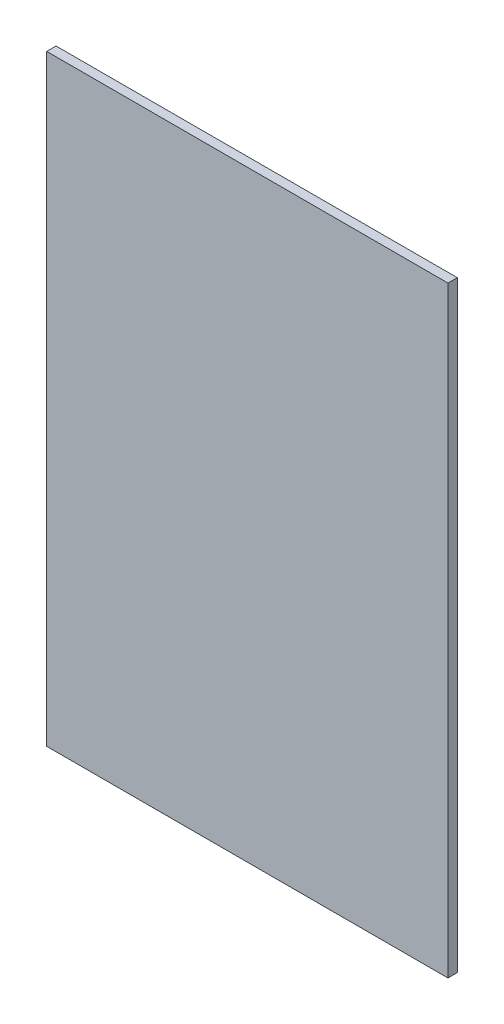
from build123d import *

# Parameters (mm, degrees)
SKETCH1_W           = 101.6
SKETCH1_H           = 152.4
BOSS_EXTRUDE1_DEPTH = 2.3622


with BuildPart() as part:
    # Sketch1 → Boss-Extrude1 (new body)
    with BuildSketch(Plane.XY):
        with Locations((50.8, 76.2)):
            Rectangle(SKETCH1_W, SKETCH1_H)
    extrude(amount=BOSS_EXTRUDE1_DEPTH)


solid = part.part
